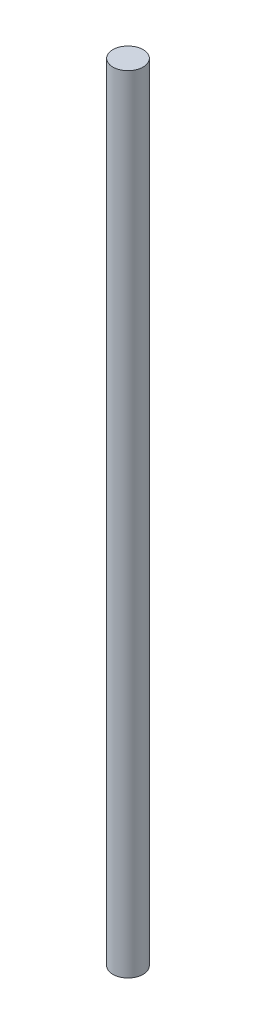
from build123d import *

# Parameters (mm, degrees)
ESQUISSE1_R        = 5
BOSS_EXTRU_1_DEPTH = 260


with BuildPart() as part:
    # Esquisse1 → Boss.-Extru.1 (new body)
    with BuildSketch(Plane(origin=(0, 0, 0), x_dir=(1, 0, 0), z_dir=(0, 1, 0))):
        Circle(ESQUISSE1_R)
    extrude(amount=BOSS_EXTRU_1_DEPTH)


solid = part.part
